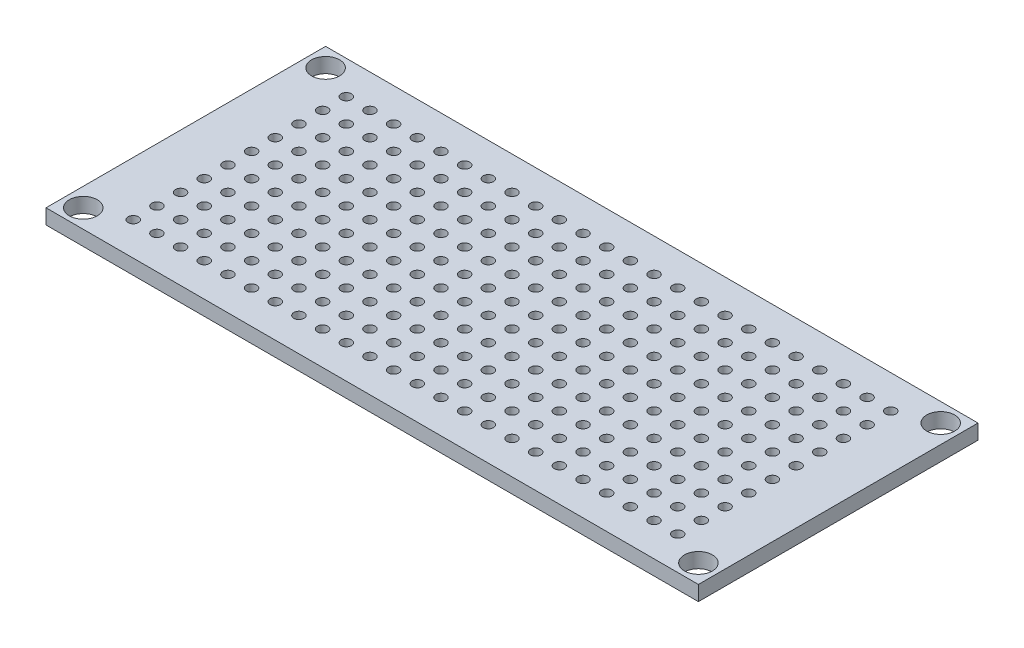
from build123d import *

# Parameters (mm, degrees)
SKETCH1_W           = 70
SKETCH1_H           = 30
SKETCH1_R           = 1.5
BOSS_EXTRUDE1_DEPTH = 1.6
SKETCH2_R           = 0.55
CUT_EXTRUDE1_DEPTH  = 1.6


with BuildPart() as part:
    # Sketch1 → Boss-Extrude1 (new body)
    with BuildSketch(Plane(origin=(0, 0, 0), x_dir=(1, 0, 0), z_dir=(0, 1, 0))):
        Rectangle(SKETCH1_W, SKETCH1_H)
        with Locations((-33, 13)):
            Circle(SKETCH1_R, mode=Mode.SUBTRACT)
        with Locations((33, 13)):
            Circle(SKETCH1_R, mode=Mode.SUBTRACT)
        with Locations((33, -13)):
            Circle(SKETCH1_R, mode=Mode.SUBTRACT)
        with Locations((-33, -13)):
            Circle(SKETCH1_R, mode=Mode.SUBTRACT)
    extrude(amount=BOSS_EXTRUDE1_DEPTH)

    # Sketch2 → Cut-Extrude1 (cut)
    with BuildSketch(Plane(origin=(0, 1.6, 0), x_dir=(1, 0, 0), z_dir=(0, 1, 0))):
        with Locations((-29.21, 11.43)):
            Circle(SKETCH2_R)
        with Locations((-26.67, 11.43)):
            Circle(SKETCH2_R)
        with Locations((-24.13, 11.43)):
            Circle(SKETCH2_R)
        with Locations((-21.59, 11.43)):
            Circle(SKETCH2_R)
        with Locations((-19.05, 11.43)):
            Circle(SKETCH2_R)
        with Locations((-16.51, 11.43)):
            Circle(SKETCH2_R)
        with Locations((-13.97, 11.43)):
            Circle(SKETCH2_R)
        with Locations((-11.43, 11.43)):
            Circle(SKETCH2_R)
        with Locations((-8.89, 11.43)):
            Circle(SKETCH2_R)
        with Locations((-6.35, 11.43)):
            Circle(SKETCH2_R)
        with Locations((-3.81, 11.43)):
            Circle(SKETCH2_R)
        with Locations((-1.27, 11.43)):
            Circle(SKETCH2_R)
        with Locations((1.27, 11.43)):
            Circle(SKETCH2_R)
        with Locations((3.81, 11.43)):
            Circle(SKETCH2_R)
        with Locations((6.35, 11.43)):
            Circle(SKETCH2_R)
        with Locations((8.89, 11.43)):
            Circle(SKETCH2_R)
        with Locations((11.43, 11.43)):
            Circle(SKETCH2_R)
        with Locations((13.97, 11.43)):
            Circle(SKETCH2_R)
        with Locations((16.51, 11.43)):
            Circle(SKETCH2_R)
        with Locations((19.05, 11.43)):
            Circle(SKETCH2_R)
        with Locations((21.59, 11.43)):
            Circle(SKETCH2_R)
        with Locations((24.13, 11.43)):
            Circle(SKETCH2_R)
        with Locations((26.67, 11.43)):
            Circle(SKETCH2_R)
        with Locations((29.21, 11.43)):
            Circle(SKETCH2_R)
        with Locations((-26.67, 8.89)):
            Circle(SKETCH2_R)
        with Locations((-24.13, 8.89)):
            Circle(SKETCH2_R)
        with Locations((-21.59, 8.89)):
            Circle(SKETCH2_R)
        with Locations((-19.05, 8.89)):
            Circle(SKETCH2_R)
        with Locations((-16.51, 8.89)):
            Circle(SKETCH2_R)
        with Locations((-13.97, 8.89)):
            Circle(SKETCH2_R)
        with Locations((-11.43, 8.89)):
            Circle(SKETCH2_R)
        with Locations((-8.89, 8.89)):
            Circle(SKETCH2_R)
        with Locations((-6.35, 8.89)):
            Circle(SKETCH2_R)
        with Locations((-3.81, 8.89)):
            Circle(SKETCH2_R)
        with Locations((-1.27, 8.89)):
            Circle(SKETCH2_R)
        with Locations((1.27, 8.89)):
            Circle(SKETCH2_R)
        with Locations((3.81, 8.89)):
            Circle(SKETCH2_R)
        with Locations((6.35, 8.89)):
            Circle(SKETCH2_R)
        with Locations((8.89, 8.89)):
            Circle(SKETCH2_R)
        with Locations((11.43, 8.89)):
            Circle(SKETCH2_R)
        with Locations((13.97, 8.89)):
            Circle(SKETCH2_R)
        with Locations((16.51, 8.89)):
            Circle(SKETCH2_R)
        with Locations((19.05, 8.89)):
            Circle(SKETCH2_R)
        with Locations((21.59, 8.89)):
            Circle(SKETCH2_R)
        with Locations((24.13, 8.89)):
            Circle(SKETCH2_R)
        with Locations((26.67, 8.89)):
            Circle(SKETCH2_R)
        with Locations((29.21, 8.89)):
            Circle(SKETCH2_R)
        with Locations((-26.67, 6.35)):
            Circle(SKETCH2_R)
        with Locations((-24.13, 6.35)):
            Circle(SKETCH2_R)
        with Locations((-21.59, 6.35)):
            Circle(SKETCH2_R)
        with Locations((-19.05, 6.35)):
            Circle(SKETCH2_R)
        with Locations((-16.51, 6.35)):
            Circle(SKETCH2_R)
        with Locations((-13.97, 6.35)):
            Circle(SKETCH2_R)
        with Locations((-11.43, 6.35)):
            Circle(SKETCH2_R)
        with Locations((-8.89, 6.35)):
            Circle(SKETCH2_R)
        with Locations((-6.35, 6.35)):
            Circle(SKETCH2_R)
        with Locations((-3.81, 6.35)):
            Circle(SKETCH2_R)
        with Locations((-1.27, 6.35)):
            Circle(SKETCH2_R)
        with Locations((1.27, 6.35)):
            Circle(SKETCH2_R)
        with Locations((3.81, 6.35)):
            Circle(SKETCH2_R)
        with Locations((6.35, 6.35)):
            Circle(SKETCH2_R)
        with Locations((8.89, 6.35)):
            Circle(SKETCH2_R)
        with Locations((11.43, 6.35)):
            Circle(SKETCH2_R)
        with Locations((13.97, 6.35)):
            Circle(SKETCH2_R)
        with Locations((16.51, 6.35)):
            Circle(SKETCH2_R)
        with Locations((19.05, 6.35)):
            Circle(SKETCH2_R)
        with Locations((21.59, 6.35)):
            Circle(SKETCH2_R)
        with Locations((24.13, 6.35)):
            Circle(SKETCH2_R)
        with Locations((26.67, 6.35)):
            Circle(SKETCH2_R)
        with Locations((29.21, 6.35)):
            Circle(SKETCH2_R)
        with Locations((-26.67, 3.81)):
            Circle(SKETCH2_R)
        with Locations((-24.13, 3.81)):
            Circle(SKETCH2_R)
        with Locations((-21.59, 3.81)):
            Circle(SKETCH2_R)
        with Locations((-19.05, 3.81)):
            Circle(SKETCH2_R)
        with Locations((-16.51, 3.81)):
            Circle(SKETCH2_R)
        with Locations((-13.97, 3.81)):
            Circle(SKETCH2_R)
        with Locations((-11.43, 3.81)):
            Circle(SKETCH2_R)
        with Locations((-8.89, 3.81)):
            Circle(SKETCH2_R)
        with Locations((-6.35, 3.81)):
            Circle(SKETCH2_R)
        with Locations((-3.81, 3.81)):
            Circle(SKETCH2_R)
        with Locations((-1.27, 3.81)):
            Circle(SKETCH2_R)
        with Locations((1.27, 3.81)):
            Circle(SKETCH2_R)
        with Locations((3.81, 3.81)):
            Circle(SKETCH2_R)
        with Locations((6.35, 3.81)):
            Circle(SKETCH2_R)
        with Locations((8.89, 3.81)):
            Circle(SKETCH2_R)
        with Locations((11.43, 3.81)):
            Circle(SKETCH2_R)
        with Locations((13.97, 3.81)):
            Circle(SKETCH2_R)
        with Locations((16.51, 3.81)):
            Circle(SKETCH2_R)
        with Locations((19.05, 3.81)):
            Circle(SKETCH2_R)
        with Locations((21.59, 3.81)):
            Circle(SKETCH2_R)
        with Locations((24.13, 3.81)):
            Circle(SKETCH2_R)
        with Locations((26.67, 3.81)):
            Circle(SKETCH2_R)
        with Locations((29.21, 3.81)):
            Circle(SKETCH2_R)
        with Locations((-26.67, 1.27)):
            Circle(SKETCH2_R)
        with Locations((-24.13, 1.27)):
            Circle(SKETCH2_R)
        with Locations((-21.59, 1.27)):
            Circle(SKETCH2_R)
        with Locations((-19.05, 1.27)):
            Circle(SKETCH2_R)
        with Locations((-16.51, 1.27)):
            Circle(SKETCH2_R)
        with Locations((-13.97, 1.27)):
            Circle(SKETCH2_R)
        with Locations((-11.43, 1.27)):
            Circle(SKETCH2_R)
        with Locations((-8.89, 1.27)):
            Circle(SKETCH2_R)
        with Locations((-6.35, 1.27)):
            Circle(SKETCH2_R)
        with Locations((-3.81, 1.27)):
            Circle(SKETCH2_R)
        with Locations((-1.27, 1.27)):
            Circle(SKETCH2_R)
        with Locations((1.27, 1.27)):
            Circle(SKETCH2_R)
        with Locations((3.81, 1.27)):
            Circle(SKETCH2_R)
        with Locations((6.35, 1.27)):
            Circle(SKETCH2_R)
        with Locations((8.89, 1.27)):
            Circle(SKETCH2_R)
        with Locations((11.43, 1.27)):
            Circle(SKETCH2_R)
        with Locations((13.97, 1.27)):
            Circle(SKETCH2_R)
        with Locations((16.51, 1.27)):
            Circle(SKETCH2_R)
        with Locations((19.05, 1.27)):
            Circle(SKETCH2_R)
        with Locations((21.59, 1.27)):
            Circle(SKETCH2_R)
        with Locations((24.13, 1.27)):
            Circle(SKETCH2_R)
        with Locations((26.67, 1.27)):
            Circle(SKETCH2_R)
        with Locations((29.21, 1.27)):
            Circle(SKETCH2_R)
        with Locations((-26.67, -1.27)):
            Circle(SKETCH2_R)
        with Locations((-24.13, -1.27)):
            Circle(SKETCH2_R)
        with Locations((-21.59, -1.27)):
            Circle(SKETCH2_R)
        with Locations((-19.05, -1.27)):
            Circle(SKETCH2_R)
        with Locations((-16.51, -1.27)):
            Circle(SKETCH2_R)
        with Locations((-13.97, -1.27)):
            Circle(SKETCH2_R)
        with Locations((-11.43, -1.27)):
            Circle(SKETCH2_R)
        with Locations((-8.89, -1.27)):
            Circle(SKETCH2_R)
        with Locations((-6.35, -1.27)):
            Circle(SKETCH2_R)
        with Locations((-3.81, -1.27)):
            Circle(SKETCH2_R)
        with Locations((-1.27, -1.27)):
            Circle(SKETCH2_R)
        with Locations((1.27, -1.27)):
            Circle(SKETCH2_R)
        with Locations((3.81, -1.27)):
            Circle(SKETCH2_R)
        with Locations((6.35, -1.27)):
            Circle(SKETCH2_R)
        with Locations((8.89, -1.27)):
            Circle(SKETCH2_R)
        with Locations((11.43, -1.27)):
            Circle(SKETCH2_R)
        with Locations((13.97, -1.27)):
            Circle(SKETCH2_R)
        with Locations((16.51, -1.27)):
            Circle(SKETCH2_R)
        with Locations((19.05, -1.27)):
            Circle(SKETCH2_R)
        with Locations((21.59, -1.27)):
            Circle(SKETCH2_R)
        with Locations((24.13, -1.27)):
            Circle(SKETCH2_R)
        with Locations((26.67, -1.27)):
            Circle(SKETCH2_R)
        with Locations((29.21, -1.27)):
            Circle(SKETCH2_R)
        with Locations((-26.67, -3.81)):
            Circle(SKETCH2_R)
        with Locations((-24.13, -3.81)):
            Circle(SKETCH2_R)
        with Locations((-21.59, -3.81)):
            Circle(SKETCH2_R)
        with Locations((-19.05, -3.81)):
            Circle(SKETCH2_R)
        with Locations((-16.51, -3.81)):
            Circle(SKETCH2_R)
        with Locations((-13.97, -3.81)):
            Circle(SKETCH2_R)
        with Locations((-11.43, -3.81)):
            Circle(SKETCH2_R)
        with Locations((-8.89, -3.81)):
            Circle(SKETCH2_R)
        with Locations((-6.35, -3.81)):
            Circle(SKETCH2_R)
        with Locations((-3.81, -3.81)):
            Circle(SKETCH2_R)
        with Locations((-1.27, -3.81)):
            Circle(SKETCH2_R)
        with Locations((1.27, -3.81)):
            Circle(SKETCH2_R)
        with Locations((3.81, -3.81)):
            Circle(SKETCH2_R)
        with Locations((6.35, -3.81)):
            Circle(SKETCH2_R)
        with Locations((8.89, -3.81)):
            Circle(SKETCH2_R)
        with Locations((11.43, -3.81)):
            Circle(SKETCH2_R)
        with Locations((13.97, -3.81)):
            Circle(SKETCH2_R)
        with Locations((16.51, -3.81)):
            Circle(SKETCH2_R)
        with Locations((19.05, -3.81)):
            Circle(SKETCH2_R)
        with Locations((21.59, -3.81)):
            Circle(SKETCH2_R)
        with Locations((24.13, -3.81)):
            Circle(SKETCH2_R)
        with Locations((26.67, -3.81)):
            Circle(SKETCH2_R)
        with Locations((29.21, -3.81)):
            Circle(SKETCH2_R)
        with Locations((-26.67, -6.35)):
            Circle(SKETCH2_R)
        with Locations((-24.13, -6.35)):
            Circle(SKETCH2_R)
        with Locations((-21.59, -6.35)):
            Circle(SKETCH2_R)
        with Locations((-19.05, -6.35)):
            Circle(SKETCH2_R)
        with Locations((-16.51, -6.35)):
            Circle(SKETCH2_R)
        with Locations((-13.97, -6.35)):
            Circle(SKETCH2_R)
        with Locations((-11.43, -6.35)):
            Circle(SKETCH2_R)
        with Locations((-8.89, -6.35)):
            Circle(SKETCH2_R)
        with Locations((-6.35, -6.35)):
            Circle(SKETCH2_R)
        with Locations((-3.81, -6.35)):
            Circle(SKETCH2_R)
        with Locations((-1.27, -6.35)):
            Circle(SKETCH2_R)
        with Locations((1.27, -6.35)):
            Circle(SKETCH2_R)
        with Locations((3.81, -6.35)):
            Circle(SKETCH2_R)
        with Locations((6.35, -6.35)):
            Circle(SKETCH2_R)
        with Locations((8.89, -6.35)):
            Circle(SKETCH2_R)
        with Locations((11.43, -6.35)):
            Circle(SKETCH2_R)
        with Locations((13.97, -6.35)):
            Circle(SKETCH2_R)
        with Locations((16.51, -6.35)):
            Circle(SKETCH2_R)
        with Locations((19.05, -6.35)):
            Circle(SKETCH2_R)
        with Locations((21.59, -6.35)):
            Circle(SKETCH2_R)
        with Locations((24.13, -6.35)):
            Circle(SKETCH2_R)
        with Locations((26.67, -6.35)):
            Circle(SKETCH2_R)
        with Locations((29.21, -6.35)):
            Circle(SKETCH2_R)
        with Locations((-26.67, -8.89)):
            Circle(SKETCH2_R)
        with Locations((-24.13, -8.89)):
            Circle(SKETCH2_R)
        with Locations((-21.59, -8.89)):
            Circle(SKETCH2_R)
        with Locations((-19.05, -8.89)):
            Circle(SKETCH2_R)
        with Locations((-16.51, -8.89)):
            Circle(SKETCH2_R)
        with Locations((-13.97, -8.89)):
            Circle(SKETCH2_R)
        with Locations((-11.43, -8.89)):
            Circle(SKETCH2_R)
        with Locations((-8.89, -8.89)):
            Circle(SKETCH2_R)
        with Locations((-6.35, -8.89)):
            Circle(SKETCH2_R)
        with Locations((-3.81, -8.89)):
            Circle(SKETCH2_R)
        with Locations((-1.27, -8.89)):
            Circle(SKETCH2_R)
        with Locations((1.27, -8.89)):
            Circle(SKETCH2_R)
        with Locations((3.81, -8.89)):
            Circle(SKETCH2_R)
        with Locations((6.35, -8.89)):
            Circle(SKETCH2_R)
        with Locations((8.89, -8.89)):
            Circle(SKETCH2_R)
        with Locations((11.43, -8.89)):
            Circle(SKETCH2_R)
        with Locations((13.97, -8.89)):
            Circle(SKETCH2_R)
        with Locations((16.51, -8.89)):
            Circle(SKETCH2_R)
        with Locations((19.05, -8.89)):
            Circle(SKETCH2_R)
        with Locations((21.59, -8.89)):
            Circle(SKETCH2_R)
        with Locations((24.13, -8.89)):
            Circle(SKETCH2_R)
        with Locations((26.67, -8.89)):
            Circle(SKETCH2_R)
        with Locations((29.21, -8.89)):
            Circle(SKETCH2_R)
        with Locations((-26.67, -11.43)):
            Circle(SKETCH2_R)
        with Locations((-24.13, -11.43)):
            Circle(SKETCH2_R)
        with Locations((-21.59, -11.43)):
            Circle(SKETCH2_R)
        with Locations((-19.05, -11.43)):
            Circle(SKETCH2_R)
        with Locations((-16.51, -11.43)):
            Circle(SKETCH2_R)
        with Locations((-13.97, -11.43)):
            Circle(SKETCH2_R)
        with Locations((-11.43, -11.43)):
            Circle(SKETCH2_R)
        with Locations((-8.89, -11.43)):
            Circle(SKETCH2_R)
        with Locations((-6.35, -11.43)):
            Circle(SKETCH2_R)
        with Locations((-3.81, -11.43)):
            Circle(SKETCH2_R)
        with Locations((-1.27, -11.43)):
            Circle(SKETCH2_R)
        with Locations((1.27, -11.43)):
            Circle(SKETCH2_R)
        with Locations((3.81, -11.43)):
            Circle(SKETCH2_R)
        with Locations((6.35, -11.43)):
            Circle(SKETCH2_R)
        with Locations((8.89, -11.43)):
            Circle(SKETCH2_R)
        with Locations((11.43, -11.43)):
            Circle(SKETCH2_R)
        with Locations((13.97, -11.43)):
            Circle(SKETCH2_R)
        with Locations((16.51, -11.43)):
            Circle(SKETCH2_R)
        with Locations((19.05, -11.43)):
            Circle(SKETCH2_R)
        with Locations((21.59, -11.43)):
            Circle(SKETCH2_R)
        with Locations((24.13, -11.43)):
            Circle(SKETCH2_R)
        with Locations((26.67, -11.43)):
            Circle(SKETCH2_R)
        with Locations((29.21, -11.43)):
            Circle(SKETCH2_R)
        with Locations((-29.21, 8.89)):
            Circle(SKETCH2_R)
        with Locations((-29.21, 6.35)):
            Circle(SKETCH2_R)
        with Locations((-29.21, 3.81)):
            Circle(SKETCH2_R)
        with Locations((-29.21, 1.27)):
            Circle(SKETCH2_R)
        with Locations((-29.21, -1.27)):
            Circle(SKETCH2_R)
        with Locations((-29.21, -3.81)):
            Circle(SKETCH2_R)
        with Locations((-29.21, -6.35)):
            Circle(SKETCH2_R)
        with Locations((-29.21, -8.89)):
            Circle(SKETCH2_R)
        with Locations((-29.21, -11.43)):
            Circle(SKETCH2_R)
    extrude(amount=-CUT_EXTRUDE1_DEPTH, mode=Mode.SUBTRACT)


solid = part.part
